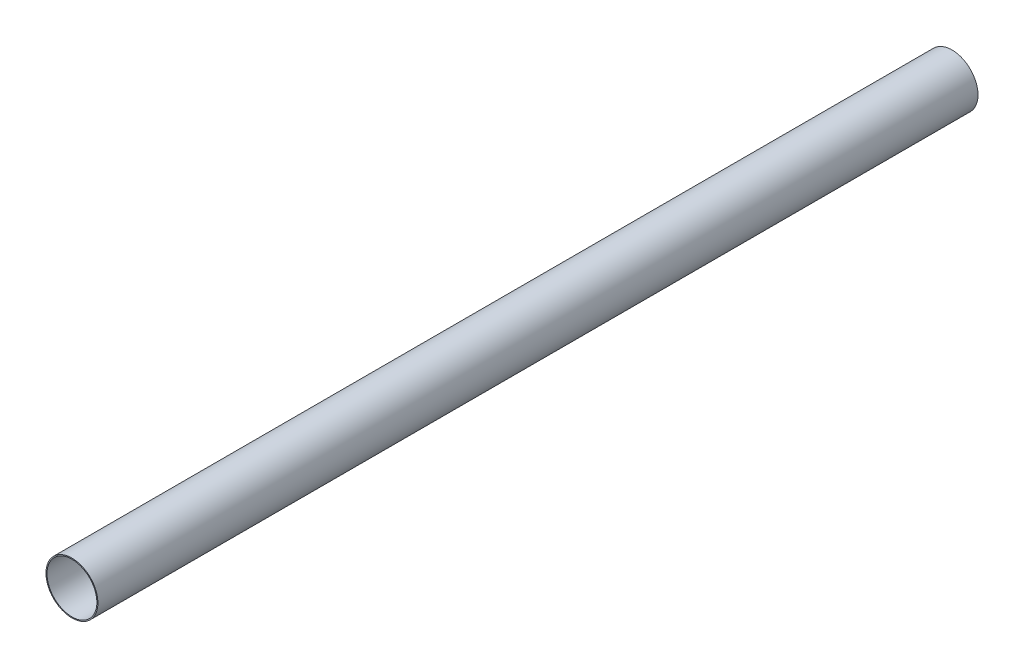
from build123d import *

# Parameters (mm, degrees)
PIPESKETCH_R    = 161.925
PIPESKETCH_R_2  = 155.575
EXTRUSION_DEPTH = 5486.4


with BuildPart() as part:
    # PipeSketch → Extrusion (new body)
    with BuildSketch(Plane.XY):
        Circle(PIPESKETCH_R)
        Circle(PIPESKETCH_R_2, mode=Mode.SUBTRACT)
    extrude(amount=EXTRUSION_DEPTH)


solid = part.part
